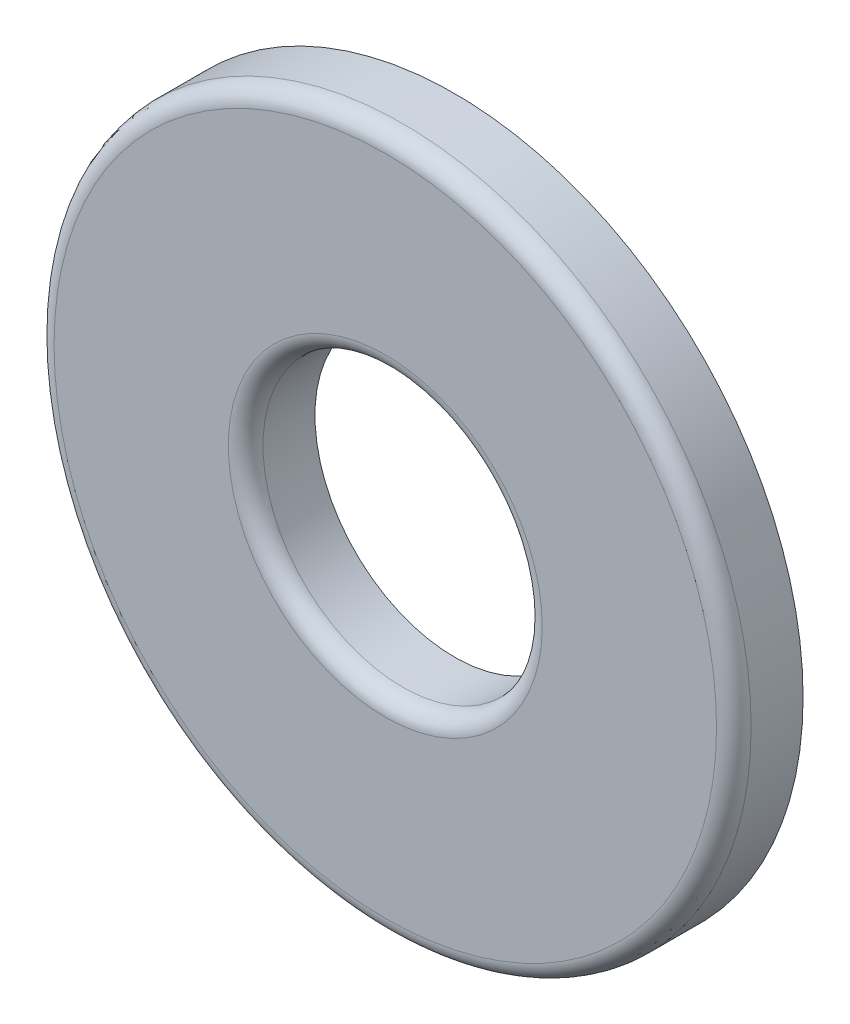
from build123d import *

# Parameters (mm, degrees)
SKETCH3_R                = 3.9624
SKETCH3_R_2              = 1.5875
BOSS_EXTRUDE1_DEPTH      = 0.3937
BOSS_EXTRUDE1_DEPTH_BACK = 0.3937
FILLET1_R                = 0.19685


with BuildPart() as part:
    # Sketch3 → Boss-Extrude1 (new body, two sides)
    with BuildSketch(Plane.XY) as boss_extrude1_sk:
        Circle(SKETCH3_R)
        Circle(SKETCH3_R_2, mode=Mode.SUBTRACT)
    extrude(amount=BOSS_EXTRUDE1_DEPTH)
    extrude(boss_extrude1_sk.sketch, amount=-BOSS_EXTRUDE1_DEPTH_BACK)

    # Fillet1
    fillet1_edges = [part.edges().sort_by_distance(p)[0] for p in [
        (-3.9624, 0, 0.3937),
        (-1.5875, 0, 0.3937),
    ]]
    fillet(fillet1_edges, radius=FILLET1_R)


solid = part.part
